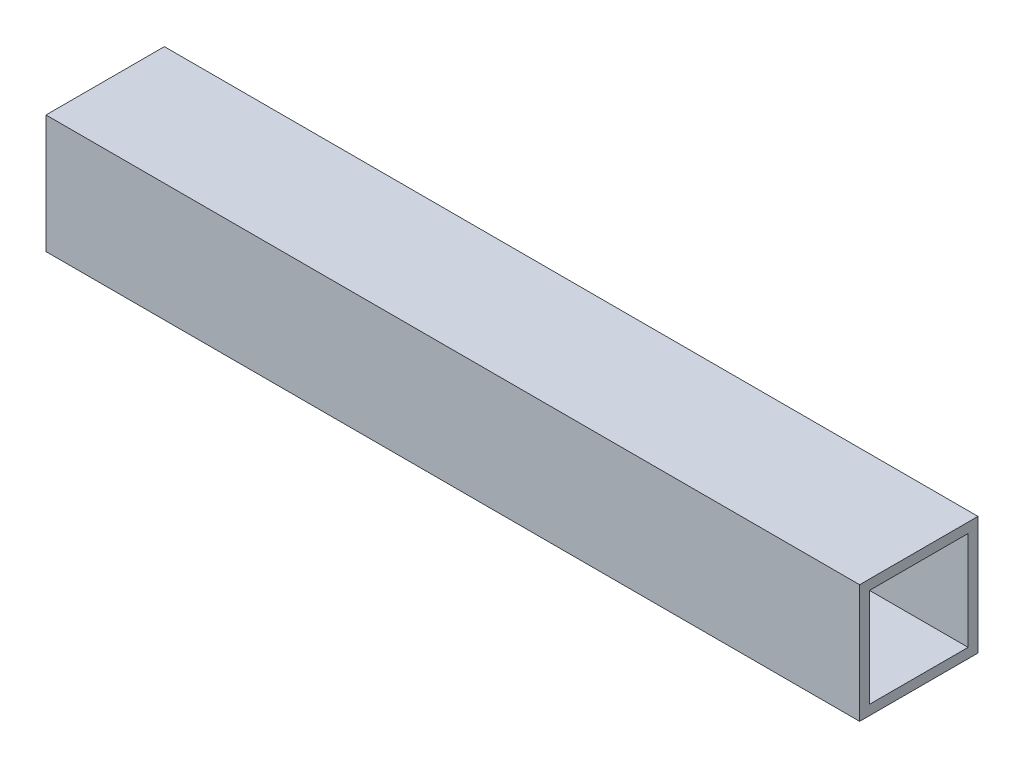
from build123d import *

# Parameters (mm, degrees)
SKETCH1_W               = 261.9
SKETCH1_H               = 38.1
BOSS_EXTRUDE1_DEPTH     = 38.1
SKETCH2_W               = 31.75
SKETCH2_H               = 31.75
CUT_EXTRUDE1_DEPTH      = 1
CUT_EXTRUDE1_DEPTH_BACK = 262.9


with BuildPart() as part:
    # Sketch1 → Boss-Extrude1 (new body)
    with BuildSketch(Plane.XY):
        with Locations((130.95, 19.05)):
            Rectangle(SKETCH1_W, SKETCH1_H)
    extrude(amount=-BOSS_EXTRUDE1_DEPTH)

    # Sketch2 → Cut-Extrude1 (cut, two sides)
    with BuildSketch(Plane(origin=(261.9, 0, 0), x_dir=(0, 0, -1), z_dir=(1, 0, 0))) as cut_extrude1_sk:
        with Locations((19.05, 19.05)):
            Rectangle(SKETCH2_W, SKETCH2_H)
    extrude(amount=CUT_EXTRUDE1_DEPTH, mode=Mode.SUBTRACT)
    extrude(cut_extrude1_sk.sketch, amount=-CUT_EXTRUDE1_DEPTH_BACK, mode=Mode.SUBTRACT)


solid = part.part
